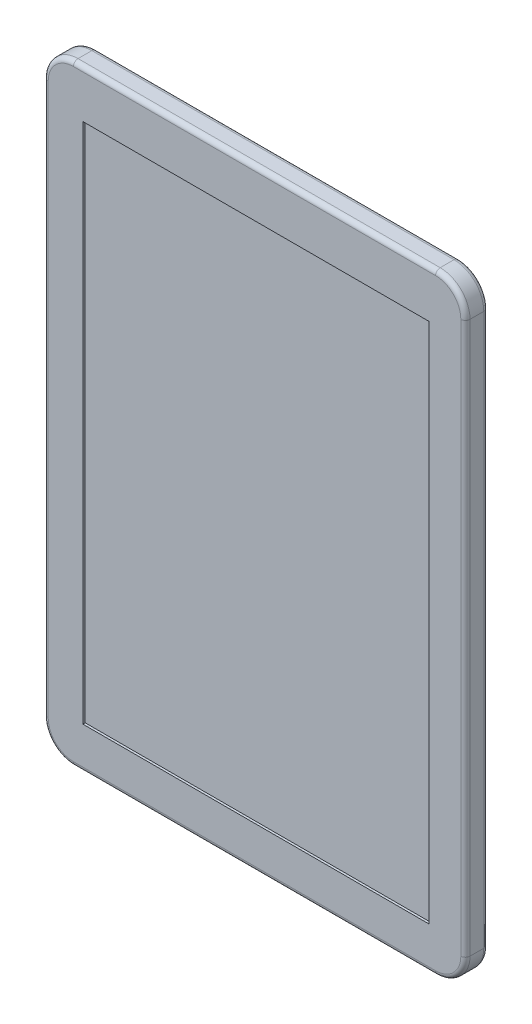
from build123d import *

# Parameters (mm, degrees)
BOSS_EXTRUDE1_DEPTH = 10
FILLET1_R           = 2
FILLET2_R           = 2
SKETCH2_W           = 150.559508978
SKETCH2_H           = 227.088218296
CUT_EXTRUDE1_DEPTH  = 1
BOSS_EXTRUDE2_DEPTH = 20
SKETCH4_W           = 6.725754883
SKETCH4_H           = 15
CUT_EXTRUDE2_DEPTH  = 5
SKETCH5_W           = 10.823402452
SKETCH5_H           = 30.328045867
SKETCH5_W_2         = 7.884028191
SKETCH5_H_2         = 2.324389301
CUT_EXTRUDE3_DEPTH  = 5
SKETCH6_R           = 4.682007924
BOSS_EXTRUDE3_DEPTH = 2
CUT_EXTRUDE4_DEPTH  = 1
SKETCH8_R           = 3.203249508
BOSS_EXTRUDE4_DEPTH = 5
SKETCH9_R           = 2.554506396
SKETCH9_R_2         = 0.710039237
CUT_EXTRUDE5_DEPTH  = 5
SKETCH10_R          = 3.699360335
CUT_EXTRUDE6_DEPTH  = 5
BOSS_EXTRUDE5_DEPTH = 2
SKETCH12_R          = 3.630842339
BOSS_EXTRUDE6_DEPTH = 4
SKETCH13_R          = 1
CUT_EXTRUDE7_DEPTH  = 2


with BuildPart() as part:
    # Sketch1 → Boss-Extrude1 (new body)
    with BuildSketch(Plane.XY):
        with BuildLine():
            Line((-10.72344857, 42.703899352), (146.86655143, 42.703899352))
            ThreePointArc((146.86655143, 42.703899352), (156.04479745, 38.902145372), (159.84655143, 29.723899352))
            Line((159.84655143, 29.723899352), (159.84655143, -210.266100648))
            ThreePointArc((159.84655143, -210.266100648), (156.04479745, -219.444346668), (146.86655143, -223.246100648))
            Line((146.86655143, -223.246100648), (-10.72344857, -223.246100648))
            ThreePointArc((-10.72344857, -223.246100648), (-19.90169459, -219.444346668), (-23.70344857, -210.266100648))
            Line((-23.70344857, -210.266100648), (-23.70344857, 29.723899352))
            ThreePointArc((-23.70344857, 29.723899352), (-19.90169459, 38.902145372), (-10.72344857, 42.703899352))
        make_face()
    extrude(amount=BOSS_EXTRUDE1_DEPTH)

    # Fillet1
    fillet1_edges = [part.edges().sort_by_distance(p)[0] for p in [
        (156.04479745, -219.444346668, 10),
        (159.84655143, -90.271100648, 10),
        (156.04479745, 38.902145372, 10),
        (68.07155143, 42.703899352, 10),
        (-19.90169459, 38.902145372, 10),
        (-23.70344857, -90.271100648, 10),
        (-19.90169459, -219.444346668, 10),
        (68.07155143, -223.246100648, 10),
    ]]
    fillet(fillet1_edges, radius=FILLET1_R)

    # Fillet2
    fillet2_edges = [part.edges().sort_by_distance(p)[0] for p in [
        (68.07155143, -223.246100648, 0),
        (-19.90169459, -219.444346668, 0),
        (-23.70344857, -90.271100648, 0),
        (-19.90169459, 38.902145372, 0),
        (68.07155143, 42.703899352, 0),
        (156.04479745, 38.902145372, 0),
        (159.84655143, -90.271100648, 0),
        (156.04479745, -219.444346668, 0),
    ]]
    fillet(fillet2_edges, radius=FILLET2_R)

    # Sketch2 → Cut-Extrude1 (cut)
    with BuildSketch(Plane.XY.offset(10)):
        with Locations((68.657611098, -91.510541064)):
            Rectangle(SKETCH2_W, SKETCH2_H)
    extrude(amount=-CUT_EXTRUDE1_DEPTH, mode=Mode.SUBTRACT)

    # Sketch3 → Boss-Extrude2 (add)
    with BuildSketch(Plane(origin=(0, 0, 0), x_dir=(-1, 0, 0), z_dir=(0, 0, -1))):
        with BuildLine():
            Line((-102.58655143, -13.276100648), (-33.54655143, -13.276100648))
            ThreePointArc((-33.54655143, -13.276100648), (-24.36830541, -17.077854628), (-20.56655143, -26.256100648))
            Line((-20.56655143, -26.256100648), (-20.56655143, -158.296100648))
            ThreePointArc((-20.56655143, -158.296100648), (-24.36830541, -167.474346668), (-33.54655143, -171.276100648))
            Line((-33.54655143, -171.276100648), (-102.58655143, -171.276100648))
            ThreePointArc((-102.58655143, -171.276100648), (-111.76479745, -167.474346668), (-115.56655143, -158.296100648))
            Line((-115.56655143, -158.296100648), (-115.56655143, -26.256100648))
            ThreePointArc((-115.56655143, -26.256100648), (-111.76479745, -17.077854628), (-102.58655143, -13.276100648))
        make_face()
    extrude(amount=BOSS_EXTRUDE2_DEPTH)

    # Sketch4 → Cut-Extrude2 (cut)
    with BuildSketch(Plane(origin=(115.56655143, 0, 0), x_dir=(0, 0, -1), z_dir=(1, 0, 0))):
        with Locations((10.383044541, -78.756100648)):
            Rectangle(SKETCH4_W, SKETCH4_H)
        with Locations((10.383044541, -98.756100648)):
            Rectangle(SKETCH4_W, SKETCH4_H)
        with Locations((10.383044541, -118.756100648)):
            Rectangle(SKETCH4_W, SKETCH4_H)
        with Locations((10.383044541, -138.756100648)):
            Rectangle(SKETCH4_W, SKETCH4_H)
    extrude(amount=-CUT_EXTRUDE2_DEPTH, mode=Mode.SUBTRACT)

    # Sketch5 → Cut-Extrude3 (cut)
    with BuildSketch(Plane(origin=(115.56655143, 0, 0), x_dir=(0, 0, -1), z_dir=(1, 0, 0))):
        with Locations((8.435417198, -48.817241241)):
            Rectangle(SKETCH5_W, SKETCH5_H)
        with Locations((8.473269779, -40.058791114)):
            Rectangle(SKETCH5_W_2, SKETCH5_H_2, mode=Mode.SUBTRACT)
        with Locations((8.473269779, -37.058791114)):
            Rectangle(SKETCH5_W_2, SKETCH5_H_2, mode=Mode.SUBTRACT)
        with Locations((8.473269779, -43.058791114)):
            Rectangle(SKETCH5_W_2, SKETCH5_H_2, mode=Mode.SUBTRACT)
        with Locations((8.473269779, -46.058791114)):
            Rectangle(SKETCH5_W_2, SKETCH5_H_2, mode=Mode.SUBTRACT)
        with Locations((8.473269779, -49.058791114)):
            Rectangle(SKETCH5_W_2, SKETCH5_H_2, mode=Mode.SUBTRACT)
        with Locations((8.473269779, -52.058791114)):
            Rectangle(SKETCH5_W_2, SKETCH5_H_2, mode=Mode.SUBTRACT)
        with Locations((8.473269779, -55.058791114)):
            Rectangle(SKETCH5_W_2, SKETCH5_H_2, mode=Mode.SUBTRACT)
        with Locations((8.473269779, -58.058791114)):
            Rectangle(SKETCH5_W_2, SKETCH5_H_2, mode=Mode.SUBTRACT)
        with Locations((8.473269779, -61.058791114)):
            Rectangle(SKETCH5_W_2, SKETCH5_H_2, mode=Mode.SUBTRACT)
    extrude(amount=-CUT_EXTRUDE3_DEPTH, mode=Mode.SUBTRACT)

    # Sketch6 → Boss-Extrude3 (add)
    with BuildSketch(Plane(origin=(115.56655143, 0, 0), x_dir=(0, 0, -1), z_dir=(1, 0, 0))):
        with Locations((9.515417979, -152.907768045)):
            Circle(SKETCH6_R)
    extrude(amount=BOSS_EXTRUDE3_DEPTH)

    # Sketch7 → Cut-Extrude4 (cut)
    with BuildSketch(Plane(origin=(117.56655143, 0, 0), x_dir=(0, 0, -1), z_dir=(1, 0, 0))):
        with BuildLine():
            ThreePointArc((11.805414658, -154.310979404), (6.626563337, -152.860959544), (11.818169697, -151.457292202))
            Line((11.818169697, -151.457292202), (12.404150804, -151.228337022))
            ThreePointArc((12.404150804, -151.228337022), (6.003985158, -152.87342514), (12.404150804, -154.518513257))
            Line((12.404150804, -154.518513257), (11.805414658, -154.310979404))
        make_face()
        with BuildLine():
            Line((12.18490875, -152.543842862), (9.037284105, -152.543842862))
            Line((9.037284105, -152.543842862), (9.037284105, -153.351490318))
            Line((9.037284105, -153.351490318), (12.163172337, -153.351490318))
            ThreePointArc((12.163172337, -153.351490318), (12.194112354, -153.113347139), (12.204451244, -152.87342514))
            ThreePointArc((12.204451244, -152.87342514), (12.199561333, -152.708344563), (12.18490875, -152.543842862))
        make_face()
        with BuildLine():
            Line((12.811043942, -152.543842862), (12.18490875, -152.543842862))
            ThreePointArc((12.18490875, -152.543842862), (12.199561333, -152.708344563), (12.204451244, -152.87342514))
            ThreePointArc((12.204451244, -152.87342514), (12.194112354, -153.113347139), (12.163172337, -153.351490318))
            Line((12.163172337, -153.351490318), (12.793339111, -153.351490318))
            ThreePointArc((12.793339111, -153.351490318), (12.818575546, -153.113049573), (12.827001565, -152.87342514))
            ThreePointArc((12.827001565, -152.87342514), (12.823009824, -152.708440956), (12.811043942, -152.543842862))
        make_face()
        with BuildLine():
            Line((13.705368282, -152.543842862), (12.811043942, -152.543842862))
            ThreePointArc((12.811043942, -152.543842862), (12.823009824, -152.708440956), (12.827001565, -152.87342514))
            ThreePointArc((12.827001565, -152.87342514), (12.818575546, -153.113049573), (12.793339111, -153.351490318))
            Line((12.793339111, -153.351490318), (13.705368282, -153.351490318))
            Line((13.705368282, -153.351490318), (13.705368282, -152.543842862))
        make_face()
    extrude(amount=-CUT_EXTRUDE4_DEPTH, mode=Mode.SUBTRACT)

    # Sketch8 → Boss-Extrude4 (add)
    with BuildSketch(Plane.XZ.offset(171.276100648)):
        with Locations((39.948285329, -5.670763906)):
            Circle(SKETCH8_R)
    extrude(amount=BOSS_EXTRUDE4_DEPTH)

    # Sketch9 → Cut-Extrude5 (cut)
    with BuildSketch(Plane.XZ.offset(176.276100648)):
        with Locations((39.948285329, -5.670763906)):
            Circle(SKETCH9_R)
        with Locations((39.948285329, -5.670763906)):
            Circle(SKETCH9_R_2, mode=Mode.SUBTRACT)
    extrude(amount=-CUT_EXTRUDE5_DEPTH, mode=Mode.SUBTRACT)

    # Sketch10 → Cut-Extrude6 (cut)
    with BuildSketch(Plane.XZ.offset(171.276100648)):
        with Locations((49.940704465, -5.30990755)):
            Circle(SKETCH10_R)
    extrude(amount=-CUT_EXTRUDE6_DEPTH, mode=Mode.SUBTRACT)

    # Sketch11 → Boss-Extrude5 (add)
    with BuildSketch(Plane.ZY.offset(-20.56655143)):
        Polygon((-6.82408612, -143.759373329), (-11.294019493, -146.340090565), (-11.294019493, -151.501525037), (-6.82408612, -154.082242272), (-2.354152748, -151.501525037), (-2.354152748, -146.340090565), align=None)
    extrude(amount=BOSS_EXTRUDE5_DEPTH)

    # Sketch12 → Boss-Extrude6 (add)
    with BuildSketch(Plane.ZY.offset(-18.56655143)):
        with Locations((-6.577483045, -148.906392161)):
            Circle(SKETCH12_R)
    extrude(amount=BOSS_EXTRUDE6_DEPTH)

    # Sketch13 → Cut-Extrude7 (cut)
    with BuildSketch(Plane(origin=(0, 0, 0), x_dir=(-1, 0, 0), z_dir=(0, 0, -1))):
        with Locations((-105.84655143, -185.246100648)):
            Circle(SKETCH13_R)
        with Locations((-30.84655143, -185.246100648)):
            Circle(SKETCH13_R)
    extrude(amount=-CUT_EXTRUDE7_DEPTH, mode=Mode.SUBTRACT)


solid = part.part
